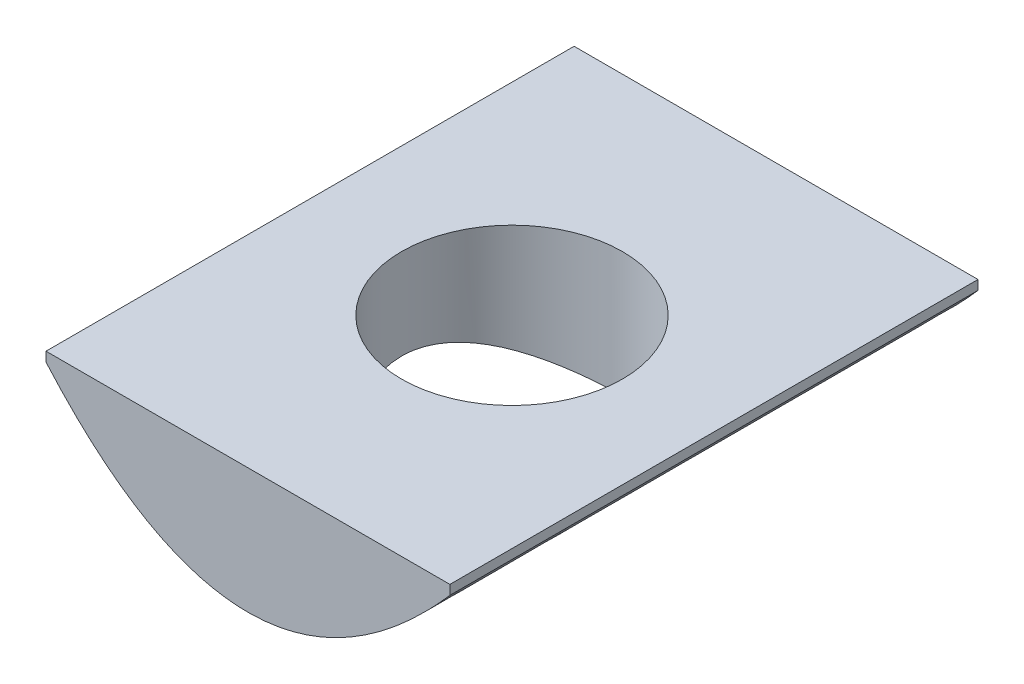
from build123d import *

# Parameters (mm, degrees)
BOSS_EXTRUDE1_DEPTH = 14.1478
SKETCH2_R           = 2.9591
CUT_EXTRUDE1_DEPTH  = 14.1478


with BuildPart() as part:
    # Sketch1 → Boss-Extrude1 (new body)
    with BuildSketch(Plane.XY):
        with BuildLine():
            Line((-5.4102, 0), (-5.4102, -0.254))
            add(Edge.make_bspline(
                [(-5.4102, -0.254), (6.345e-06, -6.451600503), (5.4102, -0.254)],
                knots=[0, 0, 0, 1, 1, 1], degree=2))
            Line((5.4102, -0.254), (5.4102, 0))
            Line((5.4102, 0), (-5.4102, 0))
        make_face()
    extrude(amount=BOSS_EXTRUDE1_DEPTH)

    # Sketch2 → Cut-Extrude1 (cut)
    with BuildSketch(Plane(origin=(0, 0, 0), x_dir=(1, 0, 0), z_dir=(0, 1, 0))):
        with Locations((0, -7.0739)):
            Circle(SKETCH2_R)
    extrude(amount=-CUT_EXTRUDE1_DEPTH, mode=Mode.SUBTRACT)


solid = part.part
